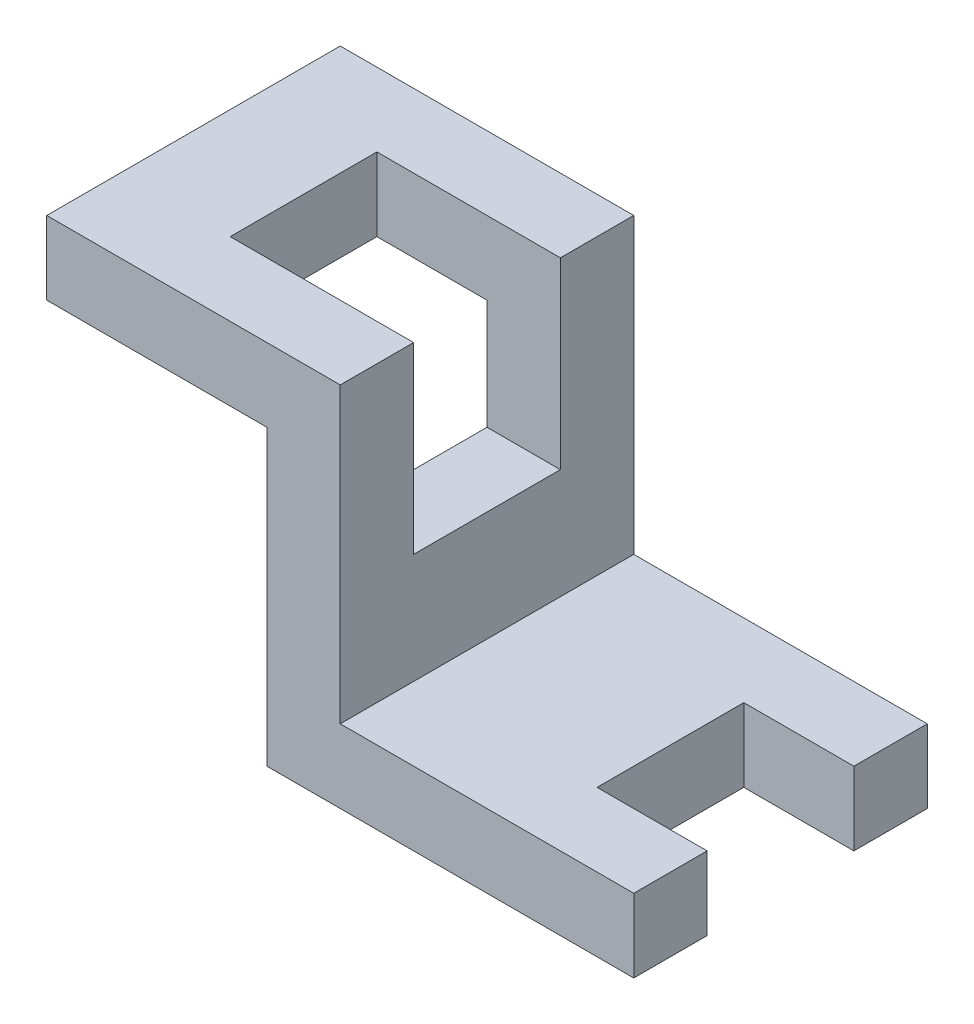
from build123d import *

# Parameters (mm, degrees)
BOSS_EXTRUDE3_DEPTH     = 40
CUT_EXTRUDE1_DEPTH      = 1
CUT_EXTRUDE1_DEPTH_BACK = 25
CUT_EXTRUDE2_DEPTH      = 11


with BuildPart() as part:
    # Sketch4 → Boss-Extrude3 (new body)
    with BuildSketch(Plane.XY):
        Polygon((0, 0), (0, -10), (30, -10), (30, -50), (80, -50), (80, -40), (40, -40), (40, 0), align=None)
    extrude(amount=BOSS_EXTRUDE3_DEPTH)

    # Sketch5 → Cut-Extrude1 (cut, two sides)
    with BuildSketch(Plane(origin=(0, 0, 0), x_dir=(1, 0, 0), z_dir=(0, 1, 0))) as cut_extrude1_sk:
        Polygon((150, -10), (40, -10), (15, -10), (15, -30), (40, -30), (150, -30), (370, -30), (370, -10), align=None)
    extrude(amount=CUT_EXTRUDE1_DEPTH, mode=Mode.SUBTRACT)
    extrude(cut_extrude1_sk.sketch, amount=-CUT_EXTRUDE1_DEPTH_BACK, mode=Mode.SUBTRACT)

    # Sketch6 → Cut-Extrude2 (cut, through all)
    with BuildSketch(Plane(origin=(0, -40, 0), x_dir=(1, 0, 0), z_dir=(0, 1, 0))):
        Polygon((260.880074906, -10), (80, -10), (65, -10), (65, -30), (80, -30), (260.880074906, -30), (622.640224719, -30), (622.640224719, -10), align=None)
    extrude(amount=-CUT_EXTRUDE2_DEPTH, mode=Mode.SUBTRACT)


solid = part.part
